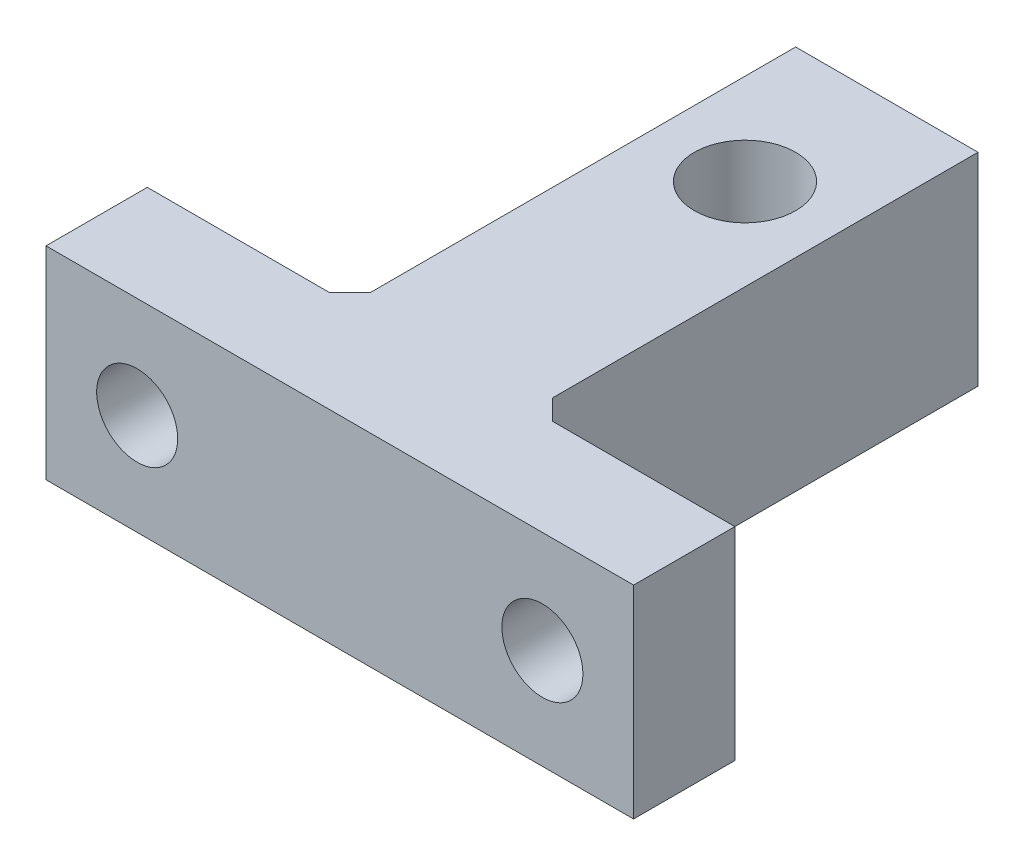
from build123d import *

# Parameters (mm, degrees)
SKETCH1_R           = 2.5
BOSS_EXTRUDE1_DEPTH = 10
SKETCH2_R           = 2
CUT_EXTRUDE1_DEPTH  = 10
SKETCH3_R           = 1.5
CUT_EXTRUDE2_DEPTH  = 4
CHAMFER1_SIZE       = 1


with BuildPart() as part:
    # Sketch1 → Boss-Extrude1 (new body)
    with BuildSketch(Plane(origin=(0, 0, 0), x_dir=(1, 0, 0), z_dir=(0, 1, 0))):
        Polygon((-1.577591036, 0), (-16.077591036, 0), (-16.077591036, 5), (-6.077591036, 5), (-6.077591036, 27), (2.922408964, 27), (2.922408964, 5), (12.922408964, 5), (12.922408964, 0), align=None)
        with Locations((-1.577591036, 20)):
            Circle(SKETCH1_R, mode=Mode.SUBTRACT)
    extrude(amount=BOSS_EXTRUDE1_DEPTH)

    # Sketch2 → Cut-Extrude1 (cut)
    with BuildSketch(Plane.XY):
        with Locations((-11.577591036, 5)):
            Circle(SKETCH2_R)
        with Locations((8.422408964, 4.9503422)):
            Circle(SKETCH2_R)
    extrude(amount=-CUT_EXTRUDE1_DEPTH, mode=Mode.SUBTRACT)

    # Sketch3 → Cut-Extrude2 (cut)
    with BuildSketch(Plane(origin=(0, 0, -27), x_dir=(-1, 0, 0), z_dir=(0, 0, -1))):
        with Locations((1.577591036, 5)):
            Circle(SKETCH3_R)
    extrude(amount=-CUT_EXTRUDE2_DEPTH, mode=Mode.SUBTRACT)

    # Chamfer1
    chamfer1_edges = [part.edges().sort_by_distance(p)[0] for p in [
        (-6.077591036, 5, -5),
        (2.922408964, 5, -5),
    ]]
    chamfer(chamfer1_edges, length=CHAMFER1_SIZE)


solid = part.part
